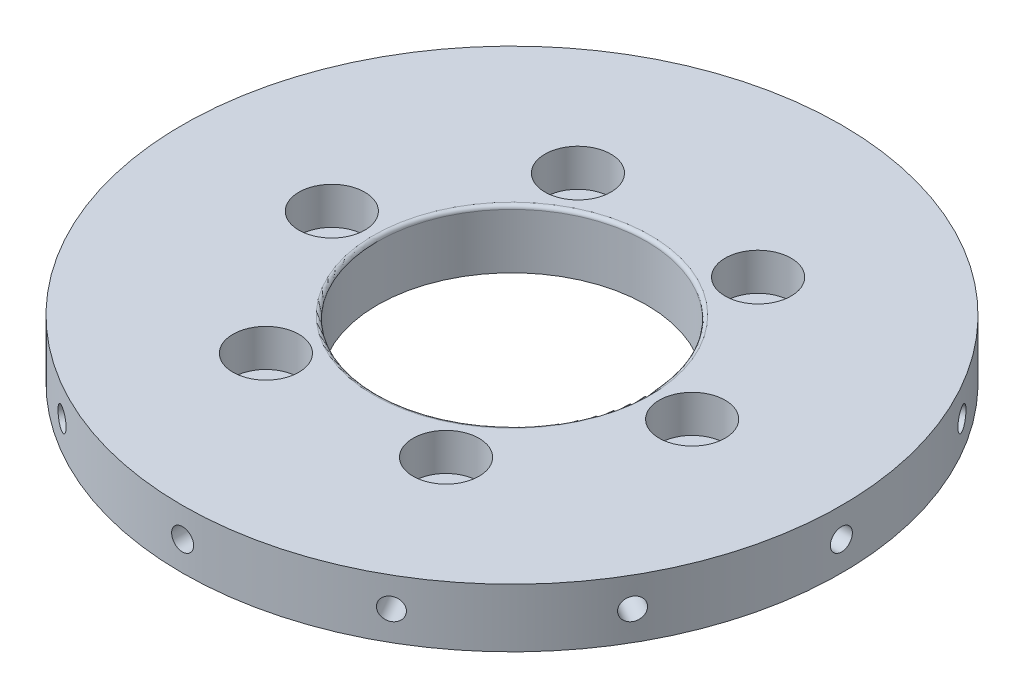
from build123d import *

# Parameters (mm, degrees)
SKETCH_1_R               = 45
SKETCH_1_R_2             = 2.5
SKETCH_1_R_3             = 18.4
EXTRUDE_1_DEPTH          = 8
SKETCH_2_R               = 4
CUT_EXTRUDE_1_DEPTH      = 3
SKETCH_4_R               = 4.5
CUT_EXTRUDE_2_DEPTH      = 5.1
SKETCH_5_R               = 1.5
CUT_EXTRUDE_3_DEPTH      = 10
PATTERN_CIRCULAR_1_COUNT = 12
FILLET_1_R               = 0.5


with BuildPart() as part:
    # 草图1 → 凸台-拉伸1 (new body)
    with BuildSketch(Plane(origin=(0, 0, 0), x_dir=(1, 0, 0), z_dir=(0, 1, 0))):
        Circle(SKETCH_1_R)
        with Locations((-24.6, 0)):
            Circle(SKETCH_1_R_2, mode=Mode.SUBTRACT)
        with Locations((-12.3, 21.304224933)):
            Circle(SKETCH_1_R_2, mode=Mode.SUBTRACT)
        with Locations((12.3, 21.304224933)):
            Circle(SKETCH_1_R_2, mode=Mode.SUBTRACT)
        with Locations((24.6, 0)):
            Circle(SKETCH_1_R_2, mode=Mode.SUBTRACT)
        with Locations((12.3, -21.304224933)):
            Circle(SKETCH_1_R_2, mode=Mode.SUBTRACT)
        with Locations((-12.3, -21.304224933)):
            Circle(SKETCH_1_R_2, mode=Mode.SUBTRACT)
        Circle(SKETCH_1_R_3, mode=Mode.SUBTRACT)
    extrude(amount=EXTRUDE_1_DEPTH)

    # 草图2 → 切除-拉伸1 (cut)
    with BuildSketch(Plane.XZ):
        with Locations((-21.304224933, -12.3)):
            Circle(SKETCH_2_R)
        with Locations((0, 24.6)):
            Circle(SKETCH_2_R)
        with Locations((21.304224933, -12.3)):
            Circle(SKETCH_2_R)
    extrude(amount=-CUT_EXTRUDE_1_DEPTH, mode=Mode.SUBTRACT)

    # 草图4 → 切除-拉伸2 (cut)
    with BuildSketch(Plane(origin=(0, 8, 0), x_dir=(1, 0, 0), z_dir=(0, 1, 0))):
        with Locations((-24.6, 0)):
            Circle(SKETCH_4_R)
        with Locations((-12.3, 21.304224933)):
            Circle(SKETCH_4_R)
        with Locations((12.3, 21.304224933)):
            Circle(SKETCH_4_R)
        with Locations((24.6, 0)):
            Circle(SKETCH_4_R)
        with Locations((12.3, -21.304224933)):
            Circle(SKETCH_4_R)
        with Locations((-12.3, -21.304224933)):
            Circle(SKETCH_4_R)
    extrude(amount=-CUT_EXTRUDE_2_DEPTH, mode=Mode.SUBTRACT)

    # 草图5 → 切除-拉伸3 (cut)
    with BuildSketch(Plane(origin=(45, 0, 0), x_dir=(0, 0, -1), z_dir=(1, 0, 0))):
        with Locations((0, 4)):
            Circle(SKETCH_5_R)
    cut_extrude_3 = extrude(amount=-CUT_EXTRUDE_3_DEPTH, mode=Mode.SUBTRACT)

    # 阵列(圆周)1: 切除-拉伸3 ×12 about axis
    pattern_circular_1_axis = Axis((0, 0, 0), (0, 1, 0))
    for i in range(1, PATTERN_CIRCULAR_1_COUNT):
        add(cut_extrude_3.rotate(pattern_circular_1_axis, i * 360 / PATTERN_CIRCULAR_1_COUNT), mode=Mode.SUBTRACT)

    # 圆角1
    fillet_1_edges = [part.edges().sort_by_distance(p)[0] for p in [
        (-18.4, 8, 0),
    ]]
    fillet(fillet_1_edges, radius=FILLET_1_R)


solid = part.part
